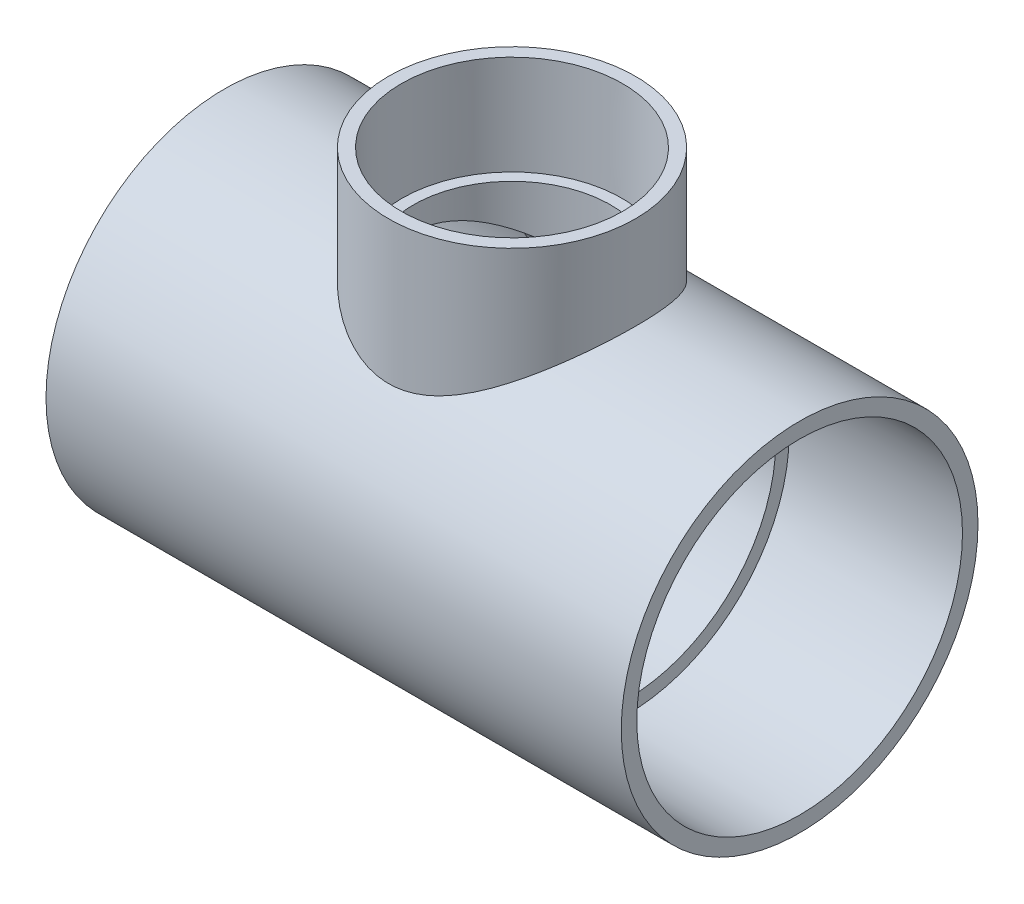
from build123d import *

# Parameters (mm, degrees)
SKETCH4_R           = 92.456
BOSS_EXTRUDE1_DEPTH = 119.38
SKETCH5_R           = 64.008
BOSS_EXTRUDE2_DEPTH = 89.408


with BuildPart() as part:
    # Sketch1 → Revolve1 (revolve)
    with BuildSketch(Plane.XY):
        Polygon((-149.098, -92.456), (-59.69, -92.456), (-59.69, -83.9978), (-149.098, -84.4169), align=None)
        Polygon((149.098, -84.4169), (59.69, -83.9978), (59.69, -92.456), (149.098, -92.456), align=None)
    revolve(axis=Axis((-149.098, 0, 0), (1, 0, 0)))



with BuildPart() as body_2:
    # Sketch2 → Revolve2 (revolve)
    with BuildSketch(Plane.XY):
        Polygon((57.3786, 140.716), (57.0357, 89.408), (64.008, 89.408), (64.008, 140.716), align=None)
    revolve(axis=Axis((0, 0, 0), (0, 1, 0)))


with BuildPart() as part_1:
    add(part.part)

    add(body_2.part)  # Boss-Extrude1 merges body 2
    # Sketch4 → Boss-Extrude1 (add)
    with BuildSketch(Plane(origin=(-59.69, 0, 0), x_dir=(0, 0, -1), z_dir=(1, 0, 0))):
        Circle(SKETCH4_R)
    extrude(amount=BOSS_EXTRUDE1_DEPTH)

    # Sketch5 → Boss-Extrude2 (add)
    with BuildSketch(Plane.XZ.offset(-89.408)):
        Circle(SKETCH5_R)
    extrude(amount=BOSS_EXTRUDE2_DEPTH)

    # Sketch6 → Cut-Revolve1 (revolve, cut)
    with BuildSketch(Plane.XY):
        Polygon((-149.098, -84.4169), (-59.69, -83.9978), (-59.69, -77.0255), (59.69, -77.0255), (59.69, -83.9978), (149.098, -84.4169), (149.098, 0), (-149.098, 0), align=None)
    revolve(axis=Axis((149.098, 0, 0), (-1, 0, 0)), mode=Mode.SUBTRACT)

    # Sketch7 → Cut-Revolve2 (revolve, cut)
    with BuildSketch(Plane.XY):
        Polygon((57.3786, 140.716), (57.0357, 89.408), (51.1302, 89.408), (51.1302, 0), (0, 0), (0, 140.716), align=None)
    revolve(axis=Axis((0, 0, 0), (0, 1, 0)), mode=Mode.SUBTRACT)


solid = part_1.part
